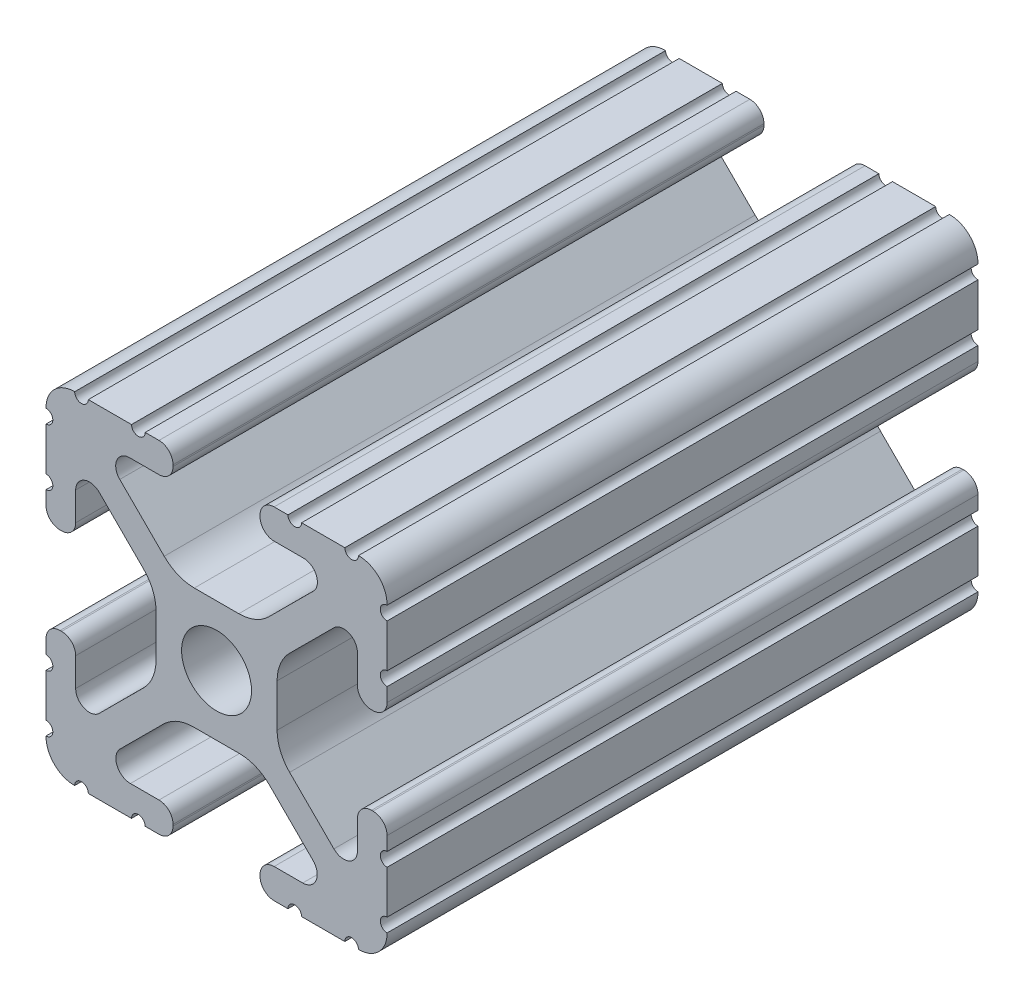
from build123d import *

# Parameters (mm, degrees)
SKETCH1_R           = 2.6035
BOSS_EXTRUDE1_DEPTH = 22


with BuildPart() as part:
    # Sketch1 → Boss-Extrude1 (new body, symmetric)
    with BuildSketch(Plane.XY):
        with BuildLine():
            Line((-7.179650497, -8.645192506), (-3.952270251, -5.423690499))
            ThreePointArc((-3.952270251, -5.423690499), (-2.922936451, -4.736929036), (-1.709253557, -4.4958))
            Line((-1.709253557, -4.4958), (1.709253557, -4.4958))
            ThreePointArc((1.709253557, -4.4958), (2.922936451, -4.736929036), (3.952270251, -5.423690499))
            Line((3.952270251, -5.423690499), (7.179650497, -8.645192506))
            ThreePointArc((7.179650497, -8.645192506), (7.41473083, -9.822813117), (6.416408329, -10.4902))
            Line((6.416408329, -10.4902), (4.287512407, -10.4902))
            ThreePointArc((4.287512407, -10.4902), (3.54574862, -10.79744862), (3.2385, -11.539212407))
            Line((3.2385, -11.539212407), (3.2385, -11.650987593))
            ThreePointArc((3.2385, -11.650987593), (3.54574862, -12.39275138), (4.287512407, -12.7))
            Line((4.287512407, -12.7), (5.317126718, -12.7))
            ThreePointArc((5.317126718, -12.7), (5.825126718, -12.192), (6.333126718, -12.7))
            Line((6.333126718, -12.7), (9.550443118, -12.7))
            ThreePointArc((9.550443118, -12.7), (10.058366869, -12.192000006), (10.566443095, -12.699847501))
            ThreePointArc((10.566443095, -12.699847501), (12.082537762, -12.08250727), (12.699846982, -10.566399977))
            ThreePointArc((12.699846982, -10.566399977), (12.192000006, -10.058323491), (12.7, -9.5504))
            Line((12.7, -9.5504), (12.7, -6.3330836))
            ThreePointArc((12.7, -6.3330836), (12.192, -5.8250836), (12.7, -5.3170836))
            Line((12.7, -5.3170836), (12.7, -4.287469289))
            ThreePointArc((12.7, -4.287469289), (12.39275138, -3.545705502), (11.650987593, -3.238456882))
            Line((11.650987593, -3.238456882), (11.539212407, -3.238456882))
            ThreePointArc((11.539212407, -3.238456882), (10.79744862, -3.545705502), (10.4902, -4.287469289))
            Line((10.4902, -4.287469289), (10.4902, -6.402089023))
            ThreePointArc((10.4902, -6.402089023), (9.856505071, -7.351067942), (8.737131347, -7.129408934))
            Line((8.737131347, -7.129408934), (5.441005833, -3.840816462))
            ThreePointArc((5.441005833, -3.840816462), (4.750877967, -2.809883091), (4.5085, -1.593185507))
            Line((4.5085, -1.593185507), (4.5085, 1.593185507))
            ThreePointArc((4.5085, 1.593185507), (4.750877967, 2.809883091), (5.441005833, 3.840816462))
            Line((5.441005833, 3.840816462), (8.737131347, 7.129408934))
            ThreePointArc((8.737131347, 7.129408934), (9.856505071, 7.351067942), (10.4902, 6.402089023))
            Line((10.4902, 6.402089023), (10.4902, 4.287469289))
            ThreePointArc((10.4902, 4.287469289), (10.79744862, 3.545705502), (11.539212407, 3.238456882))
            Line((11.539212407, 3.238456882), (11.650987593, 3.238456882))
            ThreePointArc((11.650987593, 3.238456882), (12.39275138, 3.545705502), (12.7, 4.287469289))
            Line((12.7, 4.287469289), (12.7, 5.3170836))
            ThreePointArc((12.7, 5.3170836), (12.192, 5.8250836), (12.7, 6.3330836))
            Line((12.7, 6.3330836), (12.7, 9.5504))
            ThreePointArc((12.7, 9.5504), (12.192000006, 10.058323491), (12.699846982, 10.566399977))
            ThreePointArc((12.699846982, 10.566399977), (12.082537762, 12.08250727), (10.566443095, 12.699847501))
            ThreePointArc((10.566443095, 12.699847501), (10.058366869, 12.192000006), (9.550443118, 12.7))
            Line((9.550443118, 12.7), (6.333126718, 12.7))
            ThreePointArc((6.333126718, 12.7), (5.825126718, 12.192), (5.317126718, 12.7))
            Line((5.317126718, 12.7), (4.287512407, 12.7))
            ThreePointArc((4.287512407, 12.7), (3.54574862, 12.39275138), (3.2385, 11.650987593))
            Line((3.2385, 11.650987593), (3.2385, 11.539212407))
            ThreePointArc((3.2385, 11.539212407), (3.54574862, 10.79744862), (4.287512407, 10.4902))
            Line((4.287512407, 10.4902), (6.476788598, 10.4902))
            ThreePointArc((6.476788598, 10.4902), (7.432222385, 9.85140422), (7.207036008, 8.724370562))
            Line((7.207036008, 8.724370562), (3.898272566, 5.423169045))
            ThreePointArc((3.898272566, 5.423169045), (2.869120213, 4.736787962), (1.655778399, 4.4958))
            Line((1.655778399, 4.4958), (-1.655778399, 4.4958))
            ThreePointArc((-1.655778399, 4.4958), (-2.869120213, 4.736787962), (-3.898272566, 5.423169045))
            Line((-3.898272566, 5.423169045), (-7.207036008, 8.724370562))
            ThreePointArc((-7.207036008, 8.724370562), (-7.432222385, 9.85140422), (-6.476788598, 10.4902))
            Line((-6.476788598, 10.4902), (-4.287512407, 10.4902))
            ThreePointArc((-4.287512407, 10.4902), (-3.54574862, 10.79744862), (-3.2385, 11.539212407))
            Line((-3.2385, 11.539212407), (-3.2385, 11.650987593))
            ThreePointArc((-3.2385, 11.650987593), (-3.54574862, 12.39275138), (-4.287512407, 12.7))
            Line((-4.287512407, 12.7), (-5.317126718, 12.7))
            ThreePointArc((-5.317126718, 12.7), (-5.825126718, 12.192), (-6.333126718, 12.7))
            Line((-6.333126718, 12.7), (-9.550443118, 12.7))
            ThreePointArc((-9.550443118, 12.7), (-10.058366869, 12.192000006), (-10.566443095, 12.699847501))
            ThreePointArc((-10.566443095, 12.699847501), (-12.082537762, 12.08250727), (-12.699846982, 10.566399977))
            ThreePointArc((-12.699846982, 10.566399977), (-12.192000006, 10.058323491), (-12.7, 9.5504))
            Line((-12.7, 9.5504), (-12.7, 6.3330836))
            ThreePointArc((-12.7, 6.3330836), (-12.192, 5.8250836), (-12.7, 5.3170836))
            Line((-12.7, 5.3170836), (-12.7, 4.287469289))
            ThreePointArc((-12.7, 4.287469289), (-12.39275138, 3.545705502), (-11.650987593, 3.238456882))
            Line((-11.650987593, 3.238456882), (-11.539212407, 3.238456882))
            ThreePointArc((-11.539212407, 3.238456882), (-10.79744862, 3.545705502), (-10.4902, 4.287469289))
            Line((-10.4902, 4.287469289), (-10.4902, 6.402089023))
            ThreePointArc((-10.4902, 6.402089023), (-9.856505071, 7.351067942), (-8.737131347, 7.129408934))
            Line((-8.737131347, 7.129408934), (-5.441005833, 3.840816462))
            ThreePointArc((-5.441005833, 3.840816462), (-4.750877967, 2.809883091), (-4.5085, 1.593185507))
            Line((-4.5085, 1.593185507), (-4.5085, -1.593185507))
            ThreePointArc((-4.5085, -1.593185507), (-4.750877967, -2.809883091), (-5.441005833, -3.840816462))
            Line((-5.441005833, -3.840816462), (-8.737131347, -7.129408934))
            ThreePointArc((-8.737131347, -7.129408934), (-9.856505071, -7.351067942), (-10.4902, -6.402089023))
            Line((-10.4902, -6.402089023), (-10.4902, -4.287469289))
            ThreePointArc((-10.4902, -4.287469289), (-10.79744862, -3.545705502), (-11.539212407, -3.238456882))
            Line((-11.539212407, -3.238456882), (-11.650987593, -3.238456882))
            ThreePointArc((-11.650987593, -3.238456882), (-12.39275138, -3.545705502), (-12.7, -4.287469289))
            Line((-12.7, -4.287469289), (-12.7, -5.3170836))
            ThreePointArc((-12.7, -5.3170836), (-12.192, -5.8250836), (-12.7, -6.3330836))
            Line((-12.7, -6.3330836), (-12.7, -9.5504))
            ThreePointArc((-12.7, -9.5504), (-12.192000006, -10.058323491), (-12.699846982, -10.566399977))
            ThreePointArc((-12.699846982, -10.566399977), (-12.082537762, -12.08250727), (-10.566443095, -12.699847501))
            ThreePointArc((-10.566443095, -12.699847501), (-10.058366869, -12.192000006), (-9.550443118, -12.7))
            Line((-9.550443118, -12.7), (-6.333126718, -12.7))
            ThreePointArc((-6.333126718, -12.7), (-5.825126718, -12.192), (-5.317126718, -12.7))
            Line((-5.317126718, -12.7), (-4.287512407, -12.7))
            ThreePointArc((-4.287512407, -12.7), (-3.54574862, -12.39275138), (-3.2385, -11.650987593))
            Line((-3.2385, -11.650987593), (-3.2385, -11.539212407))
            ThreePointArc((-3.2385, -11.539212407), (-3.54574862, -10.79744862), (-4.287512407, -10.4902))
            Line((-4.287512407, -10.4902), (-6.416408329, -10.4902))
            ThreePointArc((-6.416408329, -10.4902), (-7.41473083, -9.822813117), (-7.179650497, -8.645192506))
        make_face()
        Circle(SKETCH1_R, mode=Mode.SUBTRACT)
    extrude(amount=BOSS_EXTRUDE1_DEPTH, both=True)


solid = part.part
